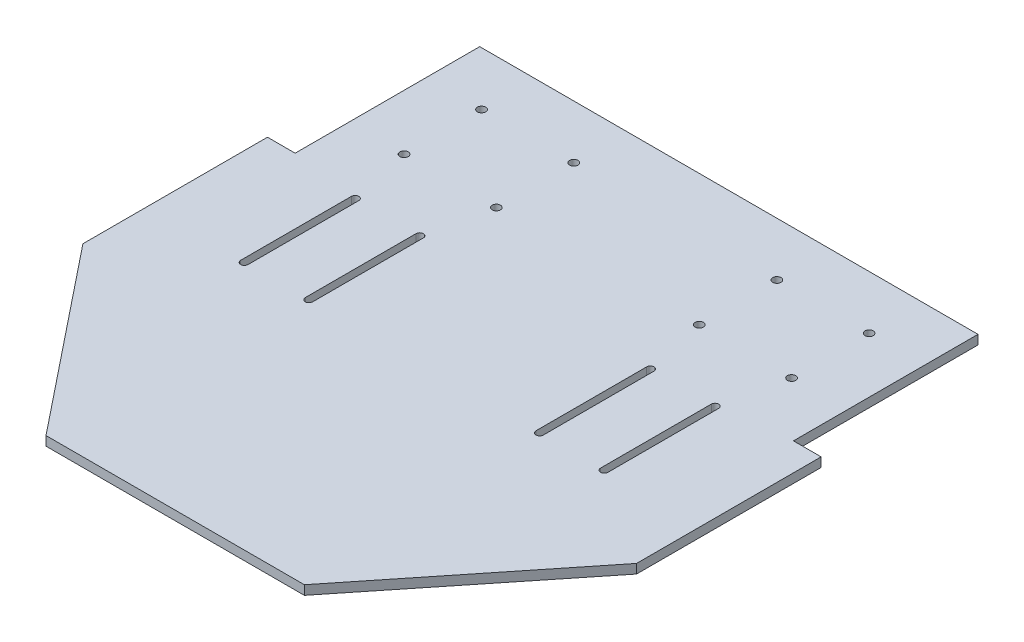
from build123d import *

# Parameters (mm, degrees)
SKETCH_2_R          = 2.25
EXTRUDE_2_DEPTH     = 5
SKETCH_3_W          = 15
SKETCH_3_H          = 100
CUT_EXTRUDE_1_DEPTH = 5
CUT_EXTRUDE_2_DEPTH = 5


with BuildPart() as part:
    # 草圖2 → 填料-伸長2 (new body)
    with BuildSketch(Plane(origin=(0, 0, 0), x_dir=(1, 0, 0), z_dir=(0, 1, 0))):
        Polygon((-150, 150), (150, 150), (150, -50), (70, -150), (-70, -150), (-150, -50), align=None)
        with Locations((-105, 121)):
            Circle(SKETCH_2_R, mode=Mode.SUBTRACT)
        with Locations((-105, 79)):
            Circle(SKETCH_2_R, mode=Mode.SUBTRACT)
        with Locations((-55, 79)):
            Circle(SKETCH_2_R, mode=Mode.SUBTRACT)
        with Locations((-55, 121)):
            Circle(SKETCH_2_R, mode=Mode.SUBTRACT)
        with Locations((55, 121)):
            Circle(SKETCH_2_R, mode=Mode.SUBTRACT)
        with Locations((55, 79)):
            Circle(SKETCH_2_R, mode=Mode.SUBTRACT)
        with Locations((105, 121)):
            Circle(SKETCH_2_R, mode=Mode.SUBTRACT)
        with Locations((105, 79)):
            Circle(SKETCH_2_R, mode=Mode.SUBTRACT)
    extrude(amount=EXTRUDE_2_DEPTH)

    # 草圖3 → 除料-伸長1 (cut)
    with BuildSketch(Plane(origin=(0, 5, 0), x_dir=(1, 0, 0), z_dir=(0, 1, 0))):
        with Locations((-142.5, 100)):
            Rectangle(SKETCH_3_W, SKETCH_3_H)
        with Locations((142.5, 100)):
            Rectangle(SKETCH_3_W, SKETCH_3_H)
    extrude(amount=-CUT_EXTRUDE_1_DEPTH, mode=Mode.SUBTRACT)

    # 草圖4 → 除料-伸長2 (cut)
    with BuildSketch(Plane(origin=(0, 5, 0), x_dir=(1, 0, 0), z_dir=(0, 1, 0))):
        with BuildLine():
            Line((-95.5, 45), (-95.5, -15))
            ThreePointArc((-95.5, -15), (-97.5, -17), (-99.5, -15))
            Line((-99.5, -15), (-99.5, 45))
            ThreePointArc((-99.5, 45), (-97.5, 47), (-95.5, 45))
        make_face()
        with BuildLine():
            Line((-64.5, 45), (-64.5, -15))
            ThreePointArc((-64.5, -15), (-62.5, -17), (-60.5, -15))
            Line((-60.5, -15), (-60.5, 45))
            ThreePointArc((-60.5, 45), (-62.5, 47), (-64.5, 45))
        make_face()
        with BuildLine():
            Line((95.5, 45), (95.5, -15))
            ThreePointArc((95.5, -15), (97.5, -17), (99.5, -15))
            Line((99.5, -15), (99.5, 45))
            ThreePointArc((99.5, 45), (97.5, 47), (95.5, 45))
        make_face()
        with BuildLine():
            Line((64.5, 45), (64.5, -15))
            ThreePointArc((64.5, -15), (62.5, -17), (60.5, -15))
            Line((60.5, -15), (60.5, 45))
            ThreePointArc((60.5, 45), (62.5, 47), (64.5, 45))
        make_face()
    extrude(amount=-CUT_EXTRUDE_2_DEPTH, mode=Mode.SUBTRACT)


solid = part.part
